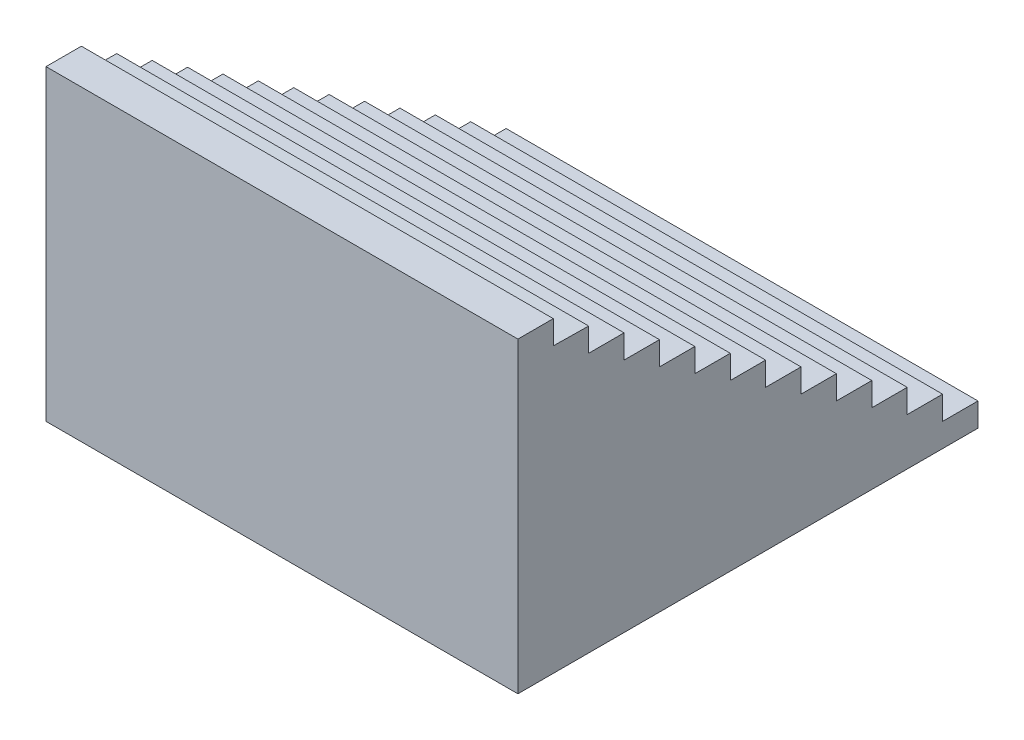
from build123d import *

# Parameters (mm, degrees)
BOSS_EXTRUDE1_DEPTH = 200


with BuildPart() as part:
    # Sketch1 → Boss-Extrude1 (new body)
    with BuildSketch(Plane(origin=(0, 0, 0), x_dir=(0, 0, -1), z_dir=(1, 0, 0))):
        Polygon((-75, 65.21314577), (-60, 65.21314577), (-60, 55.21314577), (-45.001514141, 55.000021516), (-45.001514141, 45.000021516), (-30.001514141, 45.000021516), (-30.001514141, 35.000021516), (-15.001514141, 35.000021516), (-15.001514141, 25.000021516), (-0.001514141, 25.000021516), (-0.001514141, 15.000021516), (14.998485859, 15.000021516), (14.998485859, 5.000021516), (29.998485859, 5.000021516), (29.998485859, -4.999978484), (44.998485859, -4.999978484), (44.998485859, -14.999978484), (59.998485859, -14.999978484), (59.998485859, -24.999978484), (74.998485859, -24.999978484), (74.998485859, -34.999978484), (89.998485859, -34.999978484), (89.998485859, -44.999978484), (104.998485859, -44.999978484), (104.998485859, -54.999978484), (119.998485859, -54.999978484), (119.998485859, -64.999978484), (-75, -64.999978484), align=None)
    extrude(amount=-BOSS_EXTRUDE1_DEPTH)


solid = part.part
